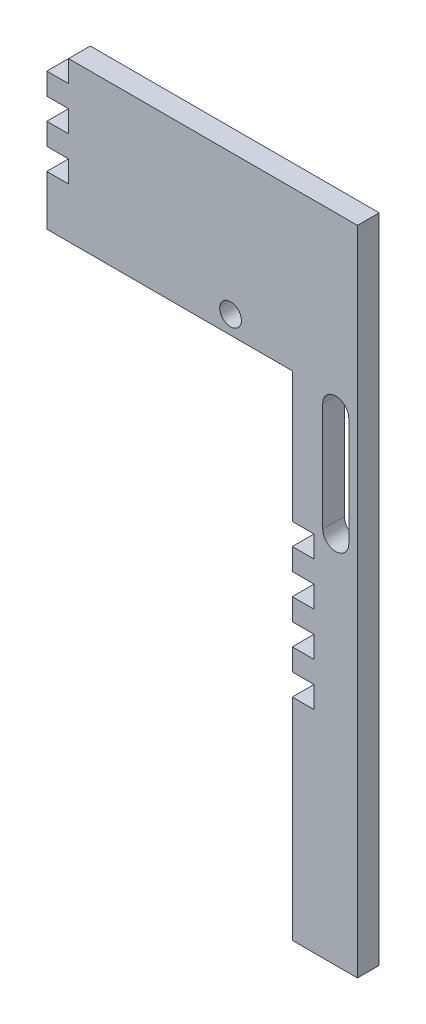
from build123d import *

# Parameters (mm, degrees)
BOSS_EXTRU_1_DEPTH         = 10
ESQUISSE2_W                = 10
ESQUISSE2_H                = 10
ENL_V_MAT_EXTRU_1_DEPTH    = 10
R_P_TITION_LIN_AIRE1_COUNT = 3
R_P_TITION_LIN_AIRE1_PITCH = 20
ESQUISSE3_W                = 10
ESQUISSE3_H                = 10
ENL_V_MAT_EXTRU_2_DEPTH    = 10
R_P_TITION_LIN_AIRE2_COUNT = 4
R_P_TITION_LIN_AIRE2_PITCH = 20
ENL_V_MAT_EXTRU_3_DEPTH    = 10
ESQUISSE5_R                = 5
ENL_V_MAT_EXTRU_4_DEPTH    = 10


with BuildPart() as part:
    # Esquisse1 → Boss.-Extru.1 (new body)
    with BuildSketch(Plane.XY):
        Polygon((0, 0), (-30, 0), (-30, 227), (-143, 227), (-143, 300), (0, 300), align=None)
    extrude(amount=BOSS_EXTRU_1_DEPTH)

    # Esquisse2 → Enlèv. mat.-Extru.1 (cut)
    with BuildSketch(Plane.XY.offset(10)):
        with Locations((-138, 295)):
            Rectangle(ESQUISSE2_W, ESQUISSE2_H)
    enl_v_mat_extru_1 = extrude(amount=-ENL_V_MAT_EXTRU_1_DEPTH, mode=Mode.SUBTRACT)

    # Répétition linéaire1: Enlèv. mat.-Extru.1 ×3
    with Locations(*[(0, -i * R_P_TITION_LIN_AIRE1_PITCH, 0) for i in range(1, R_P_TITION_LIN_AIRE1_COUNT)]):
        add(enl_v_mat_extru_1, mode=Mode.SUBTRACT)

    # Esquisse3 → Enlèv. mat.-Extru.2 (cut)
    with BuildSketch(Plane.XY.offset(10)):
        with Locations((-25, 162)):
            Rectangle(ESQUISSE3_W, ESQUISSE3_H)
    enl_v_mat_extru_2 = extrude(amount=-ENL_V_MAT_EXTRU_2_DEPTH, mode=Mode.SUBTRACT)

    # Répétition linéaire2: Enlèv. mat.-Extru.2 ×4
    with Locations(*[(0, -i * R_P_TITION_LIN_AIRE2_PITCH, 0) for i in range(1, R_P_TITION_LIN_AIRE2_COUNT)]):
        add(enl_v_mat_extru_2, mode=Mode.SUBTRACT)

    # Esquisse4 → Enlèv. mat.-Extru.3 (cut)
    with BuildSketch(Plane.XY.offset(10)):
        with BuildLine():
            Line((-4, 221), (-4, 171))
            ThreePointArc((-4, 171), (-10, 165), (-16, 171))
            Line((-16, 171), (-16, 221))
            ThreePointArc((-16, 221), (-10, 227), (-4, 221))
        make_face()
    extrude(amount=-ENL_V_MAT_EXTRU_3_DEPTH, mode=Mode.SUBTRACT)

    # Esquisse5 → Enlèv. mat.-Extru.4 (cut)
    with BuildSketch(Plane.XY.offset(10)):
        with Locations((-58.415926493, 235.370461514)):
            Circle(ESQUISSE5_R)
    extrude(amount=-ENL_V_MAT_EXTRU_4_DEPTH, mode=Mode.SUBTRACT)


solid = part.part
